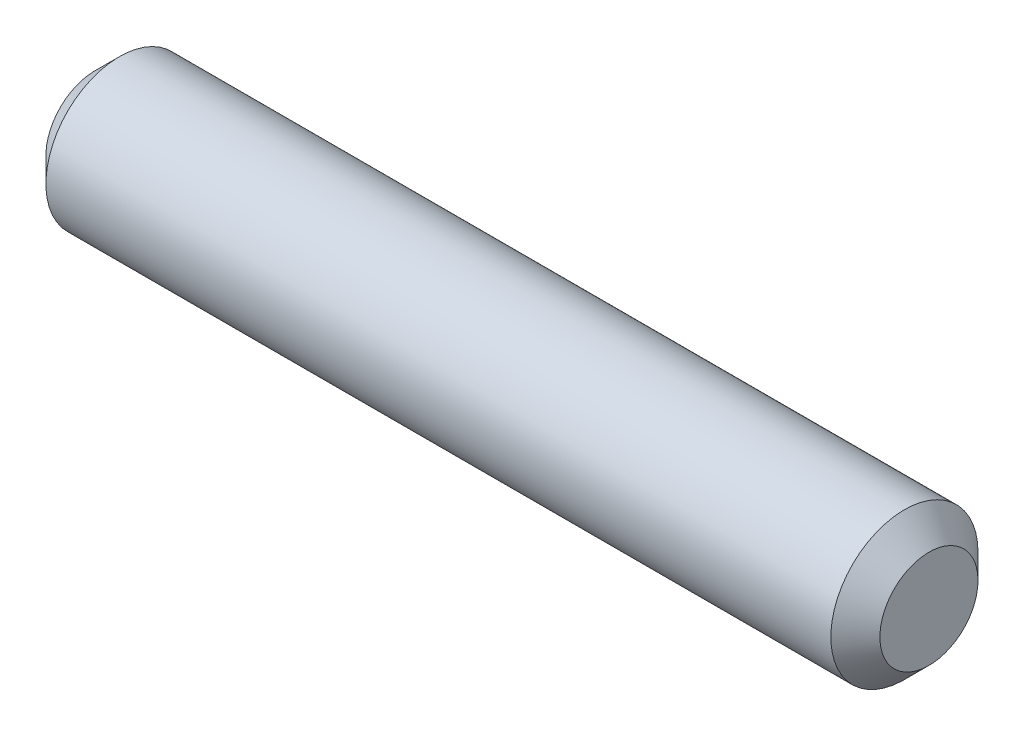
from build123d import *

# Parameters (mm, degrees)
ESQUISSE1_R     = 1.5
AXE_DEPTH       = 8.5
CHANFREIN1_SIZE = 0.5


with BuildPart() as part:
    # Esquisse1 → AXE (new body, symmetric)
    with BuildSketch(Plane(origin=(0, 0, 0), x_dir=(0, 0, -1), z_dir=(1, 0, 0))):
        Circle(ESQUISSE1_R)
    extrude(amount=AXE_DEPTH, both=True)

    # Chanfrein1
    chanfrein1_edges = [part.edges().sort_by_distance(p)[0] for p in [
        (-8.5, 0, 1.5),
        (8.5, 0, 1.5),
    ]]
    chamfer(chanfrein1_edges, length=CHANFREIN1_SIZE)


solid = part.part
